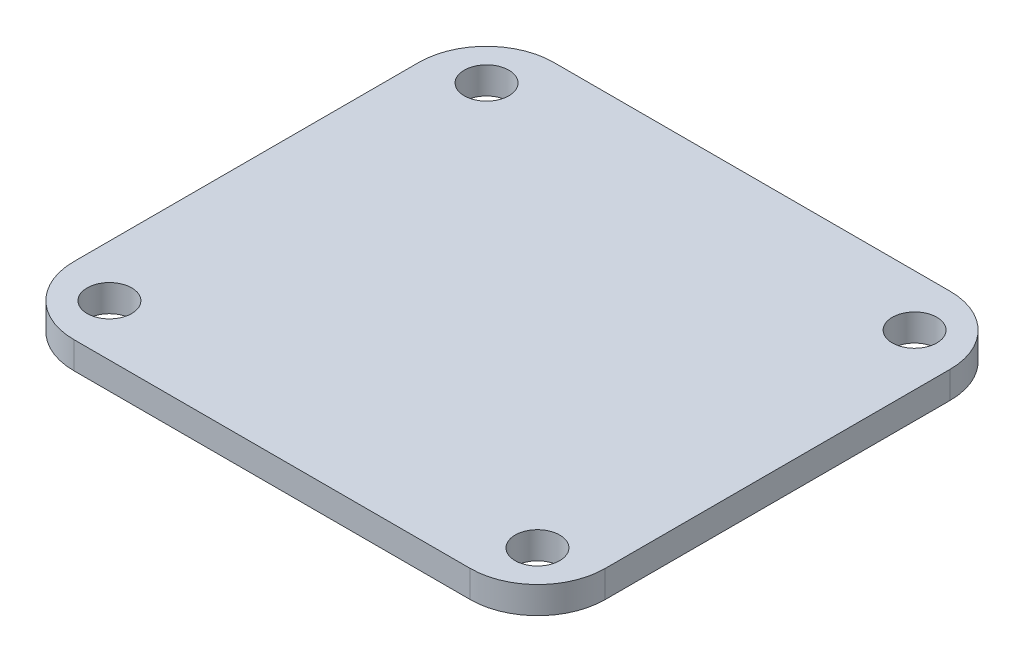
from build123d import *

# Parameters (mm, degrees)
ESQUISSE1_W        = 39.37
ESQUISSE1_H        = 35.56
ESQUISSE1_R        = 1.65
BOSS_EXTRU_1_DEPTH = 2
CONG_2_R           = 5


with BuildPart() as part:
    # Esquisse1 → Boss.-Extru.1 (new body)
    with BuildSketch(Plane(origin=(0, 0, 0), x_dir=(1, 0, 0), z_dir=(0, 1, 0))):
        Rectangle(ESQUISSE1_W, ESQUISSE1_H)
        with Locations((-15.855, 13.97)):
            Circle(ESQUISSE1_R, mode=Mode.SUBTRACT)
        with Locations((15.855, 13.97)):
            Circle(ESQUISSE1_R, mode=Mode.SUBTRACT)
        with Locations((-15.855, -13.97)):
            Circle(ESQUISSE1_R, mode=Mode.SUBTRACT)
        with Locations((15.855, -13.97)):
            Circle(ESQUISSE1_R, mode=Mode.SUBTRACT)
    extrude(amount=BOSS_EXTRU_1_DEPTH)

    # Congé2
    cong_2_edges = [part.edges().sort_by_distance(p)[0] for p in [
        (19.685, 1, 17.78),
        (-19.685, 1, 17.78),
        (-19.685, 1, -17.78),
        (19.685, 1, -17.78),
    ]]
    fillet(cong_2_edges, radius=CONG_2_R)


solid = part.part
